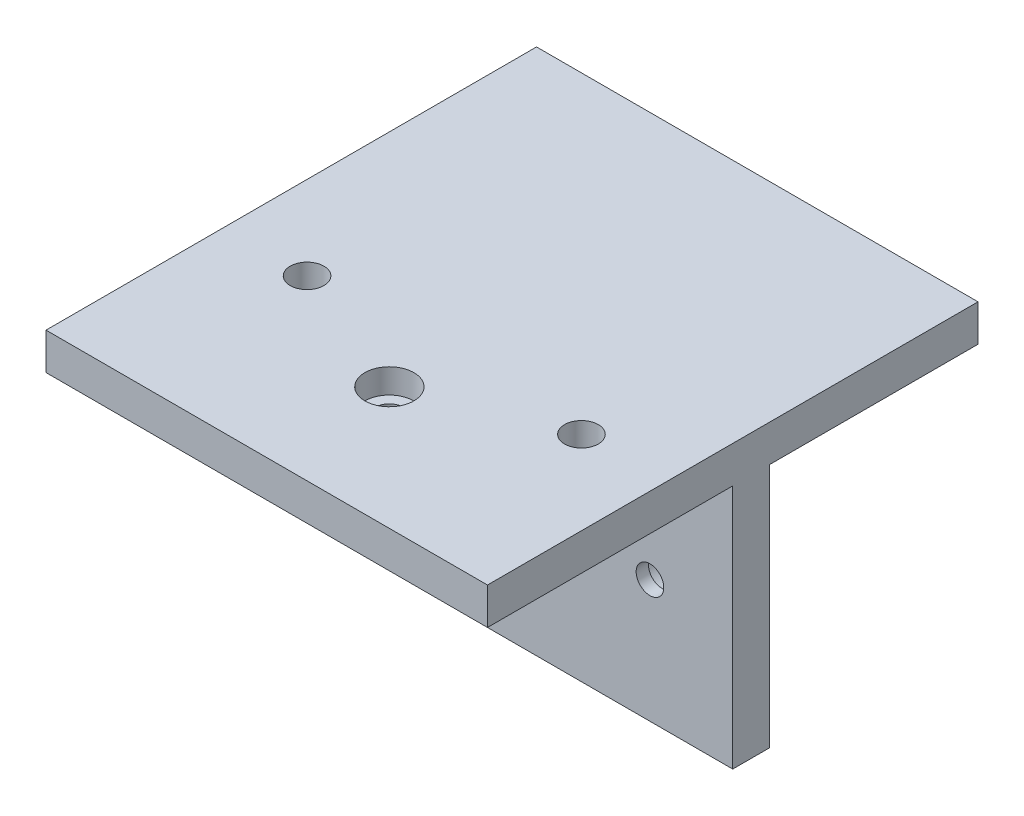
from build123d import *

# Parameters (mm, degrees)
BOSS_EXTRUDE1_DEPTH = 36
CUT_EXTRUDE1_REACH  = 48
SKETCH2_R           = 2.25
CUT_EXTRUDE2_REACH  = 8
SKETCH3_R           = 2.25
SKETCH4_R           = 4
CUT_EXTRUDE3_DEPTH  = 4
SKETCH5_R           = 4
CUT_EXTRUDE4_DEPTH  = 4
CUT_EXTRUDE5_REACH  = 48
SKETCH7_R           = 2.25
SKETCH8_R           = 2.75
CUT_EXTRUDE6_DEPTH  = 4
BOSS_EXTRUDE2_DEPTH = 3


with BuildPart() as part:
    # Sketch1 → Boss-Extrude1 (new body, symmetric)
    with BuildSketch(Plane(origin=(0, 0, 0), x_dir=(0, 0, -1), z_dir=(1, 0, 0))):
        Polygon((-20, 20), (20, 20), (20, -20), (26, -20), (26, 20), (60, 20), (60, 26), (-20, 26), align=None)
    extrude(amount=BOSS_EXTRUDE1_DEPTH, both=True)

    # Sketch2 → Cut-Extrude1 (cut, up to next)
    with BuildSketch(Plane(origin=(0, 0, -26), x_dir=(-1, 0, 0), z_dir=(0, 0, -1)), mode=Mode.PRIVATE) as cut_extrude1_sk1:
        with Locations((-22.5, 0)):
            Circle(SKETCH2_R)
    cut_extrude1_tool1 = extrude(cut_extrude1_sk1.sketch, amount=-CUT_EXTRUDE1_REACH, mode=Mode.PRIVATE) & part.part
    add(cut_extrude1_tool1.solids().sort_by_distance((22.5, 0, -26))[0], mode=Mode.SUBTRACT)
    # Sketch2 → Cut-Extrude1 (cut, up to next)
    with BuildSketch(Plane(origin=(0, 0, -26), x_dir=(-1, 0, 0), z_dir=(0, 0, -1)), mode=Mode.PRIVATE) as cut_extrude1_sk2:
        with Locations((22.5, 0)):
            Circle(SKETCH2_R)
    cut_extrude1_tool2 = extrude(cut_extrude1_sk2.sketch, amount=-CUT_EXTRUDE1_REACH, mode=Mode.PRIVATE) & part.part
    add(cut_extrude1_tool2.solids().sort_by_distance((-22.5, 0, -26))[0], mode=Mode.SUBTRACT)

    # Sketch3 → Cut-Extrude2 (cut, up to next)
    with BuildSketch(Plane.XZ.offset(-20), mode=Mode.PRIVATE) as cut_extrude2_sk1:
        Circle(SKETCH3_R)
    cut_extrude2_tool1 = extrude(cut_extrude2_sk1.sketch, amount=-CUT_EXTRUDE2_REACH, mode=Mode.PRIVATE) & part.part
    add(cut_extrude2_tool1.solids().sort_by_distance((0, 20, 0))[0], mode=Mode.SUBTRACT)

    # Sketch4 → Cut-Extrude3 (cut)
    with BuildSketch(Plane(origin=(0, 0, -26), x_dir=(-1, 0, 0), z_dir=(0, 0, -1))):
        with Locations((-22.5, 0)):
            Circle(SKETCH4_R)
        with Locations((22.5, 0)):
            Circle(SKETCH4_R)
    extrude(amount=-CUT_EXTRUDE3_DEPTH, mode=Mode.SUBTRACT)

    # Sketch5 → Cut-Extrude4 (cut)
    with BuildSketch(Plane(origin=(0, 26, 0), x_dir=(1, 0, 0), z_dir=(0, 1, 0))):
        Circle(SKETCH5_R)
    extrude(amount=-CUT_EXTRUDE4_DEPTH, mode=Mode.SUBTRACT)

    # Sketch7 → Cut-Extrude5 (cut, up to next)
    with BuildSketch(Plane(origin=(0, 26, 0), x_dir=(1, 0, 0), z_dir=(0, 1, 0)), mode=Mode.PRIVATE) as cut_extrude5_sk1:
        with Locations((-22.375, 8.95)):
            Circle(SKETCH7_R)
    cut_extrude5_tool1 = extrude(cut_extrude5_sk1.sketch, amount=-CUT_EXTRUDE5_REACH, mode=Mode.PRIVATE) & part.part
    add(cut_extrude5_tool1.solids().sort_by_distance((-22.375, 26, -8.95))[0], mode=Mode.SUBTRACT)
    # Sketch7 → Cut-Extrude5 (cut, up to next)
    with BuildSketch(Plane(origin=(0, 26, 0), x_dir=(1, 0, 0), z_dir=(0, 1, 0)), mode=Mode.PRIVATE) as cut_extrude5_sk2:
        with Locations((22.375, 8.95)):
            Circle(SKETCH7_R)
    cut_extrude5_tool2 = extrude(cut_extrude5_sk2.sketch, amount=-CUT_EXTRUDE5_REACH, mode=Mode.PRIVATE) & part.part
    add(cut_extrude5_tool2.solids().sort_by_distance((22.375, 26, -8.95))[0], mode=Mode.SUBTRACT)

    # Sketch8 → Cut-Extrude6 (cut)
    with BuildSketch(Plane(origin=(0, 26, 0), x_dir=(1, 0, 0), z_dir=(0, 1, 0))):
        with Locations((-22.375, 8.95)):
            Circle(SKETCH8_R)
        with Locations((22.375, 8.95)):
            Circle(SKETCH8_R)
    extrude(amount=-CUT_EXTRUDE6_DEPTH, mode=Mode.SUBTRACT)

    # Sketch9 → Boss-Extrude2 (add, symmetric)
    with BuildSketch(Plane(origin=(0, 0, 0), x_dir=(0, 0, -1), z_dir=(1, 0, 0))):
        Polygon((26, -20), (60, 20), (26, 20), align=None)
    extrude(amount=BOSS_EXTRUDE2_DEPTH, both=True)


solid = part.part
